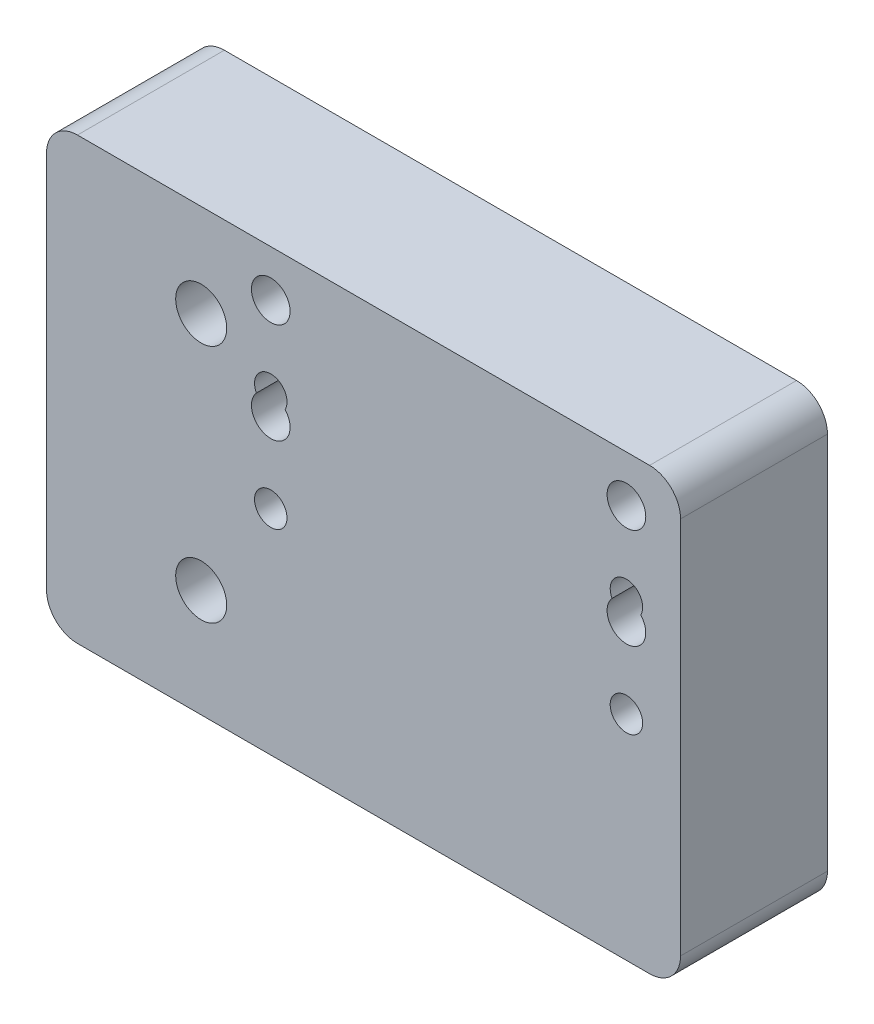
from build123d import *

# Parameters (mm, degrees)
SKETCH1_W                                           = 81.999999998
SKETCH1_H                                           = 60
BOSS_EXTRUDE1_DEPTH                                 = 19
TAP_DRILL_FOR_M6_TAP1_D                             = 5
CSK_FOR_M6_COUNTERSUNK_FLAT_HEAD_SCREW1_D           = 6.6
CSK_FOR_M6_COUNTERSUNK_FLAT_HEAD_SCREW1_CSINK_D     = 12.6
CSK_FOR_M6_COUNTERSUNK_FLAT_HEAD_SCREW1_CSINK_ANGLE = 90
SKETCH7_W                                           = 81.999999998
SKETCH7_H                                           = 4
CUT_EXTRUDE1_DEPTH                                  = 20
SKETCH10_W                                          = 81.999999998
SKETCH10_H                                          = 0.95
BOSS_EXTRUDE2_DEPTH                                 = 19
FILLET1_R                                           = 4
TAP_DRILL_FOR_M5_TAP1_D                             = 4.2
TAP_DRILL_FOR_M5_TAP1_DEPTH                         = 30
TAP_DRILL_FOR_M5_TAP1_TIP                           = 1.2618073
TAP_DRILL_FOR_M5_TAP2_D                             = 4.2


with BuildPart() as part:
    # Sketch1 → Boss-Extrude1 (new body)
    with BuildSketch(Plane.XY):
        with Locations((20.999999999, 38.745248777)):
            Rectangle(SKETCH1_W, SKETCH1_H)
    extrude(amount=BOSS_EXTRUDE1_DEPTH)

    # Tap Drill for M6 Tap1 (through all)
    with Locations(Plane.XY.offset(19)):
        with Locations((8.999999998, 58.745248777), (54.999999998, 58.745248777), (54.999999998, 45.745248777), (8.999999998, 45.745248777)):
            Hole(TAP_DRILL_FOR_M6_TAP1_D / 2)

    # CSK for M6 Countersunk Flat Head Screw1 (through all)
    with Locations(Plane(origin=(0, 0, 0), x_dir=(1, 0, 0), z_dir=(0, 0, -1))):
        with Locations((0, -21.745248777), (0, -52.745248777)):
            CounterSinkHole(CSK_FOR_M6_COUNTERSUNK_FLAT_HEAD_SCREW1_D / 2, CSK_FOR_M6_COUNTERSUNK_FLAT_HEAD_SCREW1_CSINK_D / 2, counter_sink_angle=CSK_FOR_M6_COUNTERSUNK_FLAT_HEAD_SCREW1_CSINK_ANGLE)

    # Sketch7 → Cut-Extrude1 (cut, through all)
    with BuildSketch(Plane(origin=(0, 0, 0), x_dir=(-1, 0, 0), z_dir=(0, 0, -1))):
        with Locations((-20.999999999, 66.745248777)):
            Rectangle(SKETCH7_W, SKETCH7_H)
    extrude(amount=-CUT_EXTRUDE1_DEPTH, mode=Mode.SUBTRACT)

    # Sketch10 → Boss-Extrude2 (add)
    with BuildSketch(Plane(origin=(0, 0, 0), x_dir=(-1, 0, 0), z_dir=(0, 0, -1))):
        with Locations((-20.999999999, 8.270248777)):
            Rectangle(SKETCH10_W, SKETCH10_H)
    extrude(amount=-BOSS_EXTRUDE2_DEPTH)

    # Fillet1
    fillet1_edges = [part.edges().sort_by_distance(p)[0] for p in [
        (-20, 64.745248777, 9.5),
        (61.999999998, 64.745248777, 9.5),
        (61.999999998, 7.795248777, 9.5),
        (-20, 7.795248777, 9.5),
    ]]
    fillet(fillet1_edges, radius=FILLET1_R)

    # Tap Drill for M5 Tap1
    with Locations(Plane(origin=(0, 7.795248777, 0), x_dir=(-1, 0, 0), z_dir=(0, -1, 0))):
        with Locations((-41.999999998, -9.499999998)):
            Hole(TAP_DRILL_FOR_M5_TAP1_D / 2, depth=TAP_DRILL_FOR_M5_TAP1_DEPTH)
            with Locations((0, 0, -(TAP_DRILL_FOR_M5_TAP1_DEPTH + TAP_DRILL_FOR_M5_TAP1_TIP / 2))):  # 118° drill point
                Cone(0, TAP_DRILL_FOR_M5_TAP1_D / 2, TAP_DRILL_FOR_M5_TAP1_TIP, mode=Mode.SUBTRACT)

    # Tap Drill for M5 Tap2 (through all)
    with Locations(Plane.XY.offset(19)):
        with Locations((54.999999998, 35.395248777), (54.999999998, 48.395248777), (8.999999998, 35.395248777), (8.999999998, 48.395248777)):
            Hole(TAP_DRILL_FOR_M5_TAP2_D / 2)


solid = part.part
